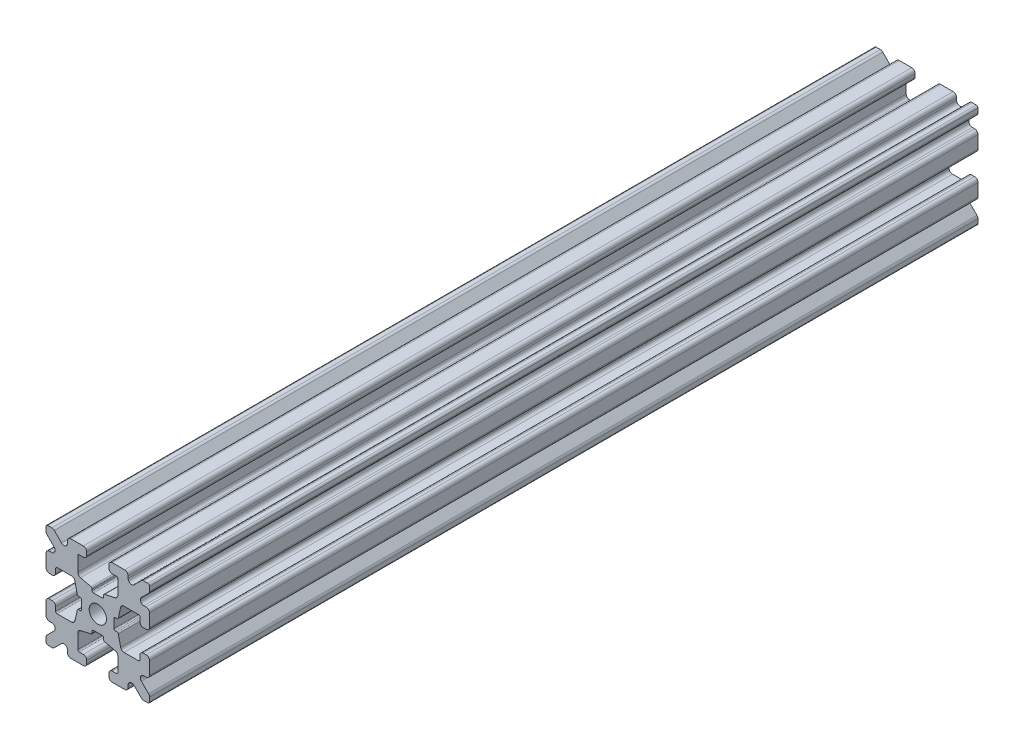
from build123d import *

# Parameters (mm, degrees)
SKETCH1_W           = 15
SKETCH1_H           = 15
SKETCH1_R           = 1.25
BOSS_EXTRUDE1_DEPTH = 60
FILLET1_R           = 0.25
CUT_EXTRUDE1_DEPTH  = 121
CUT_EXTRUDE3_DEPTH  = 121
FILLET3_R           = 0.5
FILLET4_R           = 0.5
FILLET5_R           = 3
FILLET6_R           = 0.2
CUT_EXTRUDE4_DEPTH  = 121
FILLET8_R           = 0.5
SKETCH6_W           = 5.1529354
SKETCH6_H           = 1.651
SKETCH6_W_2         = 1.651
SKETCH6_H_2         = 5.1529354
CUT_EXTRUDE5_DEPTH  = 121
FILLET10_R          = 0.2


with BuildPart() as part:
    # Sketch1 → Boss-Extrude1 (new body, symmetric)
    with BuildSketch(Plane.XY):
        Rectangle(SKETCH1_W, SKETCH1_H)
        Circle(SKETCH1_R, mode=Mode.SUBTRACT)
    extrude(amount=BOSS_EXTRUDE1_DEPTH, both=True)

    # Fillet1
    fillet1_edges = [part.edges().sort_by_distance(p)[0] for p in [
        (7.5, -7.5, 0),
        (-7.5, -7.5, 0),
        (-7.5, 7.5, 0),
        (7.5, 7.5, 0),
    ]]
    fillet(fillet1_edges, radius=FILLET1_R)

    # Sketch2 → Cut-Extrude1 (cut, through all)
    with BuildSketch(Plane.XY.offset(60)):
        Polygon((-7.5, 1.6), (-6.1, 1.6), (-6.1, 2.9), (-3.4, 2.9), (-3.4, -2.9), (-6.1, -2.9), (-6.1, -1.6), (-7.5, -1.6), align=None)
        Polygon((2.9, 6.1), (1.6, 6.1), (1.6, 7.5), (-1.6, 7.5), (-1.6, 6.1), (-2.9, 6.1), (-2.9, 3.4), (2.9, 3.4), align=None)
        Polygon((-1.6, -7.5), (-1.6, -6.1), (-2.9, -6.1), (-2.9, -3.4), (2.9, -3.4), (2.9, -6.1), (1.6, -6.1), (1.6, -7.5), align=None)
        Polygon((6.1, -2.9), (6.1, -1.6), (7.5, -1.6), (7.5, 1.6), (6.1, 1.6), (6.1, 2.9), (3.4, 2.9), (3.4, -2.9), align=None)
    extrude(amount=-CUT_EXTRUDE1_DEPTH, mode=Mode.SUBTRACT)

    # Sketch4 → Cut-Extrude3 (cut, through all)
    with BuildSketch(Plane.XY.offset(60)):
        Polygon((-3.4, 2.9), (-2.75, 0), (-3.4, -2.9), align=None)
        Polygon((-2.9, 3.4), (0, 2.75), (2.9, 3.4), align=None)
        Polygon((3.4, 2.9), (2.75, 0), (3.4, -2.9), align=None)
        Polygon((-2.9, -3.4), (0, -2.75), (2.9, -3.4), align=None)
    extrude(amount=-CUT_EXTRUDE3_DEPTH, mode=Mode.SUBTRACT)

    # Fillet3
    fillet3_edges = [part.edges().sort_by_distance(p)[0] for p in [
        (1.6, -7.5, 0),
        (-1.6, -7.5, 0),
        (-1.6, -6.1, 0),
        (1.6, -6.1, 0),
        (6.1, 1.6, 0),
        (7.5, 1.6, 0),
        (7.5, -1.6, 0),
        (6.1, -1.6, 0),
        (-7.5, -1.6, 0),
        (-7.5, 1.6, 0),
        (-6.1, 1.6, 0),
        (-6.1, -1.6, 0),
        (-1.6, 6.1, 0),
        (-1.6, 7.5, 0),
        (1.6, 7.5, 0),
        (1.6, 6.1, 0),
    ]]
    fillet(fillet3_edges, radius=FILLET3_R)

    # Fillet4
    fillet4_edges = [part.edges().sort_by_distance(p)[0] for p in [
        (-2.9, -3.4, 0),
        (2.9, -3.4, 0),
        (3.4, -2.9, 0),
        (3.4, 2.9, 0),
        (-3.4, 2.9, 0),
        (-3.4, -2.9, 0),
        (2.9, 3.4, 0),
        (-2.9, 3.4, 0),
    ]]
    fillet(fillet4_edges, radius=FILLET4_R)

    # Fillet5
    fillet5_edges = [part.edges().sort_by_distance(p)[0] for p in [
        (-2.75, 0, 0),
        (0, 2.75, 0),
        (2.75, 0, 0),
        (0, -2.75, 0),
    ]]
    fillet(fillet5_edges, radius=FILLET5_R)

    # Fillet6
    fillet6_edges = [part.edges().sort_by_distance(p)[0] for p in [
        (-2.9, -6.1, 0),
        (2.9, -6.1, 0),
        (6.1, -2.9, 0),
        (6.1, 2.9, 0),
        (-6.1, 2.9, 0),
        (-6.1, -2.9, 0),
        (2.9, 6.1, 0),
        (-2.9, 6.1, 0),
    ]]
    fillet(fillet6_edges, radius=FILLET6_R)

    # Sketch5 → Cut-Extrude4 (cut, through all)
    with BuildSketch(Plane.XY.offset(60)):
        Polygon((-7.5, 6.439339828), (-5.460660172, 4.4), (-7.5, 4.4), align=None)
        Polygon((-6.439339828, 7.5), (-4.4, 5.460660172), (-4.4, 7.5), align=None)
        Polygon((4.4, 7.5), (6.439339828, 7.5), (4.4, 5.460660172), align=None)
        Polygon((7.5, 6.439339828), (7.5, 4.4), (5.460660172, 4.4), align=None)
        Polygon((7.5, -6.439339828), (5.460660172, -4.4), (7.5, -4.4), align=None)
        Polygon((6.439339828, -7.5), (4.4, -5.460660172), (4.4, -7.5), align=None)
        Polygon((-4.4, -7.5), (-6.439339828, -7.5), (-4.4, -5.460660172), align=None)
        Polygon((-7.5, -6.439339828), (-7.5, -4.4), (-5.460660172, -4.4), align=None)
    extrude(amount=-CUT_EXTRUDE4_DEPTH, mode=Mode.SUBTRACT)

    # Fillet8
    fillet8_edges = [part.edges().sort_by_distance(p)[0] for p in [
        (-7.5, 4.4, 0),
        (-7.5, 6.439339828, 0),
        (-5.460660172, 4.4, 0),
        (7.5, -4.4, 0),
        (7.5, -6.439339828, 0),
        (5.460660172, -4.4, 0),
        (5.460660172, 4.4, 0),
        (7.5, 6.439339828, 0),
        (7.5, 4.4, 0),
        (-4.4, 7.5, 0),
        (-4.4, 5.460660172, 0),
        (-6.439339828, 7.5, 0),
        (-5.460660172, -4.4, 0),
        (-7.5, -6.439339828, 0),
        (-7.5, -4.4, 0),
        (4.4, 5.460660172, 0),
        (4.4, 7.5, 0),
        (6.439339828, 7.5, 0),
        (6.439339828, -7.5, 0),
        (4.4, -7.5, 0),
        (4.4, -5.460660172, 0),
        (-6.439339828, -7.5, 0),
        (-4.4, -5.460660172, 0),
        (-4.4, -7.5, 0),
    ]]
    fillet(fillet8_edges, radius=FILLET8_R)

    # Sketch6 → Cut-Extrude5 (cut, through all)
    with BuildSketch(Plane.XY.offset(60)):
        with Locations((4.9235323, 0)):
            Rectangle(SKETCH6_W, SKETCH6_H)
        with Locations((0, -4.9235323)):
            Rectangle(SKETCH6_W_2, SKETCH6_H_2)
        with Locations((-4.9235323, 0)):
            Rectangle(SKETCH6_W, SKETCH6_H)
        with Locations((0, 4.9235323)):
            Rectangle(SKETCH6_W_2, SKETCH6_H_2)
    extrude(amount=-CUT_EXTRUDE5_DEPTH, mode=Mode.SUBTRACT)

    # Fillet10
    fillet10_edges = [part.edges().sort_by_distance(p)[0] for p in [
        (0.8255, -2.935025862, 0),
        (-0.8255, -2.935025862, 0),
        (0.8255, -2.3470646, 0),
        (-0.8255, -2.3470646, 0),
        (2.935025862, 0.8255, 0),
        (2.935025862, -0.8255, 0),
        (2.3470646, 0.8255, 0),
        (2.3470646, -0.8255, 0),
        (-2.935025862, -0.8255, 0),
        (-2.935025862, 0.8255, 0),
        (-2.3470646, -0.8255, 0),
        (-2.3470646, 0.8255, 0),
        (-0.8255, 2.935025862, 0),
        (0.8255, 2.935025862, 0),
        (-0.8255, 2.3470646, 0),
        (0.8255, 2.3470646, 0),
    ]]
    fillet(fillet10_edges, radius=FILLET10_R)


solid = part.part
